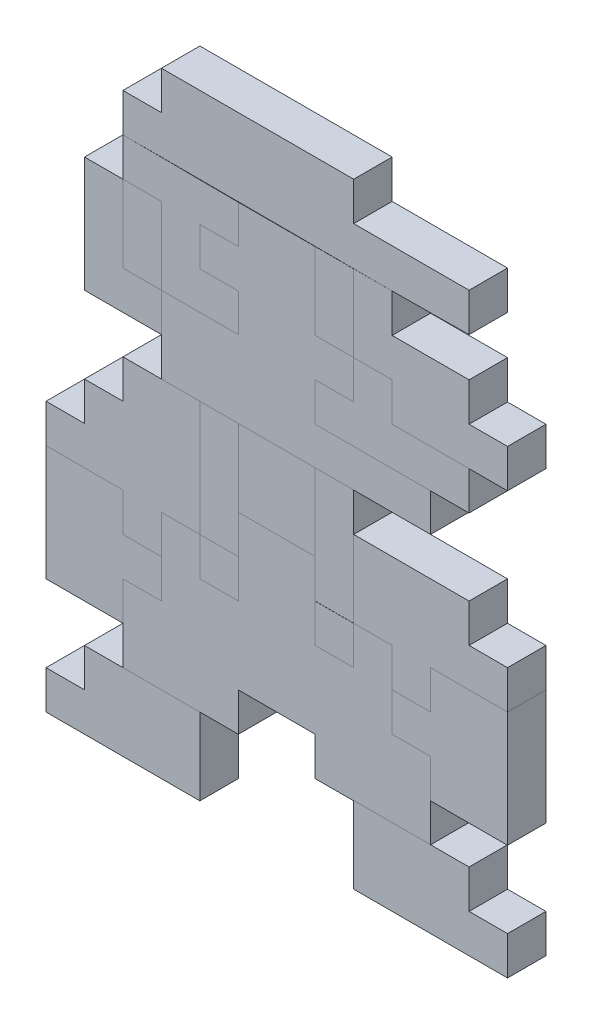
from build123d import *

# Parameters (mm, degrees)
SKETCH1_W              = 25.4
SKETCH1_H              = 50.8
BOSS_EXTRUDE1_DEPTH    = 25.4
BOSS_EXTRUDE2_DEPTH    = 25.4
BOSS_EXTRUDE10_DEPTH   = 25.4
BOSS_EXTRUDE12_DEPTH   = 25.4
BOSS_EXTRUDE13_DEPTH   = 25.4
SKETCH8_W              = 25.4
SKETCH8_H              = 50.8
BOSS_EXTRUDE14_DEPTH   = 25.4
BOSS_EXTRUDE15_DEPTH   = 25.4
BOSS_EXTRUDE16_DEPTH   = 25.4
SKETCH11_W             = 50.8
SKETCH11_H             = 50.8
BOSS_EXTRUDE17_DEPTH   = 25.4
BOSS_EXTRUDE17_2_DEPTH = 25.4
BOSS_EXTRUDE26_DEPTH   = 25.4
SKETCH23_W             = 25.4
SKETCH23_H             = 76.2
BOSS_EXTRUDE35_DEPTH   = 25.4
BOSS_EXTRUDE35_2_DEPTH = 25.4
SKETCH12_W             = 25.4
SKETCH12_H             = 25.4
BOSS_EXTRUDE36_DEPTH   = 25.4
BOSS_EXTRUDE36_2_DEPTH = 25.4
BOSS_EXTRUDE37_DEPTH   = 25.4
BOSS_EXTRUDE38_DEPTH   = 25.4
BOSS_EXTRUDE39_DEPTH   = 25.4
BOSS_EXTRUDE40_DEPTH   = 25.4
BOSS_EXTRUDE41_DEPTH   = 25.4


with BuildPart() as part:
    # Sketch1 → Boss-Extrude1 (new body)
    with BuildSketch(Plane.XY):
        with Locations((-12.7, 25.4)):
            Rectangle(SKETCH1_W, SKETCH1_H)
    extrude(amount=BOSS_EXTRUDE1_DEPTH)


with BuildPart() as body_2:
    # Sketch2 → Boss-Extrude2 (new body)
    with BuildSketch(Plane.XY.offset(25.4)):
        Polygon((0, 0), (0, -25.4), (-25.4, -25.4), (-25.4, -50.8), (76.2, -50.8), (76.2, -25.4), (25.4, -25.4), (25.4, 0), align=None)
    extrude(amount=-BOSS_EXTRUDE2_DEPTH)


with BuildPart() as body_3:
    # Sketch3 → Boss-Extrude10 (new body)
    with BuildSketch(Plane.XY.offset(25.4)):
        Polygon((76.2, -25.4), (101.6, -25.4), (101.6, 0), (76.2, 0), (76.2, 25.4), (25.4, 25.4), (25.4, 50.8), (0, 50.8), (0, 0), (25.4, 0), (25.4, -25.4), align=None)
    extrude(amount=-BOSS_EXTRUDE10_DEPTH)


with BuildPart() as body_4:
    # Sketch6 → Boss-Extrude12 (new body)
    with BuildSketch(Plane.XY.offset(25.4)):
        Polygon((-25.4, 50.8), (-76.2, 50.8), (-76.2, 25.4), (-101.6, 25.4), (-101.6, 0), (-76.2, 0), (-76.2, -24.942601225), (-127, -24.942601225), (-127, -75.742601225), (50.8, -75.742601225), (50.8, -50.8), (-25.4, -50.8), (-25.4, -25.4), (0, -25.4), (0, 0), (-25.4, 0), align=None)
    extrude(amount=-BOSS_EXTRUDE12_DEPTH)


with BuildPart() as body_5:
    # Sketch7 → Boss-Extrude13 (new body)
    with BuildSketch(Plane.XY.offset(25.4)):
        Polygon((-127, -24.942601225), (-127, 25.857398775), (-152.4, 25.857398775), (-152.4, 51.257398775), (-76.2, 50.8), (-76.2, 25.4), (-101.6, 25.4), (-101.6, 0), (-76.2, 0), (-76.2, -24.942601225), align=None)
    extrude(amount=-BOSS_EXTRUDE13_DEPTH)


with BuildPart() as body_6:
    # Sketch8 → Boss-Extrude14 (new body)
    with BuildSketch(Plane.XY.offset(25.4)):
        with Locations((-139.7, 0.457398775)):
            Rectangle(SKETCH8_W, SKETCH8_H)
    extrude(amount=-BOSS_EXTRUDE14_DEPTH)


with BuildPart() as body_7:
    # Sketch9 → Boss-Extrude15 (new body)
    with BuildSketch(Plane.XY.offset(25.4)):
        Polygon((-152.4, 25.857398775), (-152.4, -24.942601225), (-127, -24.942601225), (-127, -50.342601225), (-177.8, -50.342601225), (-177.8, 25.857398775), align=None)
    extrude(amount=-BOSS_EXTRUDE15_DEPTH)


with BuildPart() as body_8:
    # Sketch10 → Boss-Extrude16 (new body)
    with BuildSketch(Plane.XY.offset(25.4)):
        Polygon((-152.4, 51.257398775), (-152.4, 76.657398775), (-127, 76.657398775), (-127, 102.057398775), (-22.654819882, 102.057398775), (0, 102.057398775), (0, 76.657398775), (76.2, 76.657398775), (76.2, 51.257398775), (25.4, 50.8), align=None)
    extrude(amount=-BOSS_EXTRUDE16_DEPTH)


with BuildPart() as body_9:
    # Sketch11 → Boss-Extrude17 (new body)
    with BuildSketch(Plane.XY.offset(25.4)):
        with Locations((-50.8, -101.142601225)):
            Rectangle(SKETCH11_W, SKETCH11_H)
    extrude(amount=-BOSS_EXTRUDE17_DEPTH)


with BuildPart() as body_10:
    # Sketch11 → Boss-Extrude17 2 (new body)
    with BuildSketch(Plane.XY.offset(25.4)):
        Polygon((-101.6, -151.942601225), (-101.6, -75.742601225), (-127, -75.742601225), (-152.4, -75.742601225), (-152.4, -101.142601225), (-177.8, -101.142601225), (-177.8, -126.542601225), (-203.2, -126.542601225), (-203.2, -151.942601225), (-152.4, -151.942601225), (-152.4, -177.342601225), (-127, -177.342601225), (-127, -151.942601225), align=None)
    extrude(amount=-BOSS_EXTRUDE17_2_DEPTH)


with BuildPart() as body_11:
    # Sketch13 → Boss-Extrude26 (new body)
    with BuildSketch(Plane.XY.offset(25.4)):
        Polygon((-152.4, -177.342601225), (-127, -177.342601225), (-127, -202.742601225), (-152.4, -202.742601225), (-152.4, -228.142601225), (-203.2, -228.142601225), (-203.2, -151.942601225), (-152.4, -151.942601225), align=None)
    extrude(amount=-BOSS_EXTRUDE26_DEPTH)


with BuildPart() as body_12:
    # Sketch23 → Boss-Extrude35 (new body)
    with BuildSketch(Plane.XY.offset(25.4)):
        with Locations((-88.9, -113.842601225)):
            Rectangle(SKETCH23_W, SKETCH23_H)
    extrude(amount=-BOSS_EXTRUDE35_DEPTH)


with BuildPart() as body_13:
    # Sketch23 → Boss-Extrude35 2 (new body)
    with BuildSketch(Plane.XY.offset(25.4)):
        with Locations((-12.7, -113.842601225)):
            Rectangle(SKETCH23_W, SKETCH23_H)
    extrude(amount=-BOSS_EXTRUDE35_2_DEPTH)


with BuildPart() as body_14:
    # Sketch12 → Boss-Extrude36 (new body)
    with BuildSketch(Plane.XY.offset(25.4)):
        with Locations((-88.9, -164.642601225)):
            Rectangle(SKETCH12_W, SKETCH12_H)
    extrude(amount=-BOSS_EXTRUDE36_DEPTH)


with BuildPart() as body_15:
    # Sketch12 → Boss-Extrude36 2 (new body)
    with BuildSketch(Plane.XY.offset(25.4)):
        with Locations((-12.7, -164.719828194)):
            Rectangle(SKETCH12_W, SKETCH12_H)
    extrude(amount=-BOSS_EXTRUDE36_2_DEPTH)


with BuildPart() as body_16:
    # Sketch24 → Boss-Extrude37 (new body)
    with BuildSketch(Plane.XY.offset(25.4)):
        Polygon((-25.4, -126.542601225), (-76.2, -126.542601225), (-76.2, -177.342601225), (-101.6, -177.342601225), (-101.6, -151.942601225), (-127, -151.942601225), (-127, -202.742601225), (-152.4, -202.742601225), (-152.4, -253.542601225), (-76.2, -253.542601225), (-76.2, -228.142601225), (-25.4, -228.142601225), (-25.4, -253.542601225), (50.8, -253.542601225), (50.8, -202.742601225), (25.4, -202.742601225), (25.4, -151.942601225), (0, -151.942601225), (0, -177.342601225), (-25.4, -177.342601225), align=None)
    extrude(amount=-BOSS_EXTRUDE37_DEPTH)


with BuildPart() as body_17:
    # Sketch25 → Boss-Extrude38 (new body)
    with BuildSketch(Plane.XY.offset(25.4)):
        Polygon((-152.4, -253.542601225), (-177.8, -253.542601225), (-177.8, -278.942601225), (-203.2, -278.942601225), (-203.2, -304.342601225), (-101.6, -304.342601225), (-101.6, -253.542601225), align=None)
    extrude(amount=-BOSS_EXTRUDE38_DEPTH)


with BuildPart() as body_18:
    # Sketch26 → Boss-Extrude39 (new body)
    with BuildSketch(Plane.XY.offset(25.4)):
        Polygon((50.8, -253.26839435), (76.2, -253.26839435), (76.2, -278.66839435), (101.6, -278.66839435), (101.6, -304.06839435), (0, -304.06839435), (0, -253.26839435), align=None)
    extrude(amount=-BOSS_EXTRUDE39_DEPTH)


with BuildPart() as body_19:
    # Sketch27 → Boss-Extrude40 (new body)
    with BuildSketch(Plane.XY.offset(25.4)):
        Polygon((25.4, -151.942601225), (0, -151.942601225), (0, -101.142601225), (76.2, -101.142601225), (76.2, -126.542601225), (101.6, -126.542601225), (101.6, -151.942601225), (50.8, -151.942601225), (50.8, -177.342601225), (25.4, -177.342601225), align=None)
    extrude(amount=-BOSS_EXTRUDE40_DEPTH)


with BuildPart() as body_20:
    # Sketch28 → Boss-Extrude41 (new body)
    with BuildSketch(Plane.XY.offset(25.4)):
        Polygon((25.4, -177.342601225), (50.8, -177.342601225), (50.8, -151.942601225), (101.6, -151.942601225), (101.6, -228.142601225), (50.8, -228.142601225), (50.8, -202.742601225), (25.4, -202.742601225), align=None)
    extrude(amount=-BOSS_EXTRUDE41_DEPTH)


solid = Compound([part.part, body_2.part, body_3.part, body_4.part, body_5.part, body_6.part, body_7.part, body_8.part, body_9.part, body_10.part, body_11.part, body_12.part, body_13.part, body_14.part, body_15.part, body_16.part, body_17.part, body_18.part, body_19.part, body_20.part])
